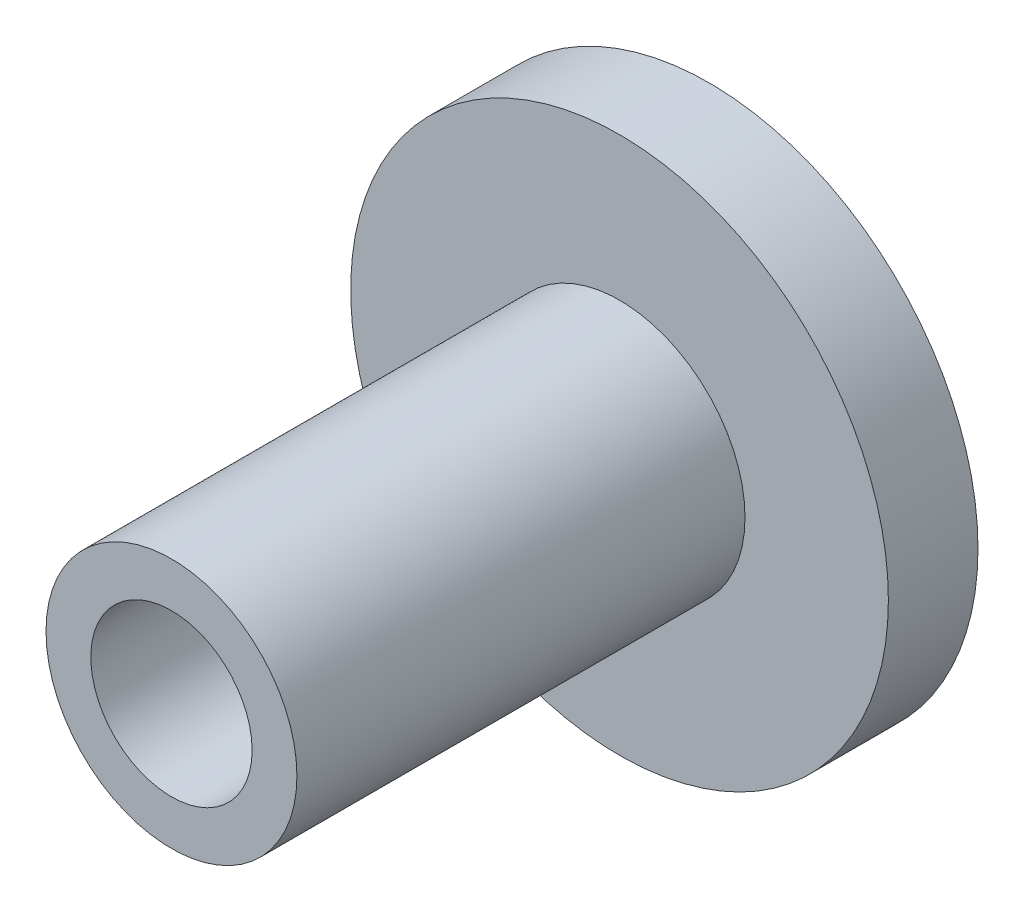
from build123d import *

# Parameters (mm, degrees)
SKETCH1_R           = 15
BOSS_EXTRUDE1_DEPTH = 5
SKETCH2_R           = 7
BOSS_EXTRUDE2_DEPTH = 25
SKETCH4_R           = 4.5
CUT_EXTRUDE2_DEPTH  = 20


with BuildPart() as part:
    # Sketch1 → Boss-Extrude1 (new body)
    with BuildSketch(Plane.XY):
        Circle(SKETCH1_R)
    extrude(amount=BOSS_EXTRUDE1_DEPTH)

    # Sketch2 → Boss-Extrude2 (add)
    with BuildSketch(Plane.XY.offset(5)):
        Circle(SKETCH2_R)
    extrude(amount=BOSS_EXTRUDE2_DEPTH)

    # Sketch4 → Cut-Extrude2 (cut)
    with BuildSketch(Plane.XY.offset(30)):
        Circle(SKETCH4_R)
    extrude(amount=-CUT_EXTRUDE2_DEPTH, mode=Mode.SUBTRACT)


solid = part.part
